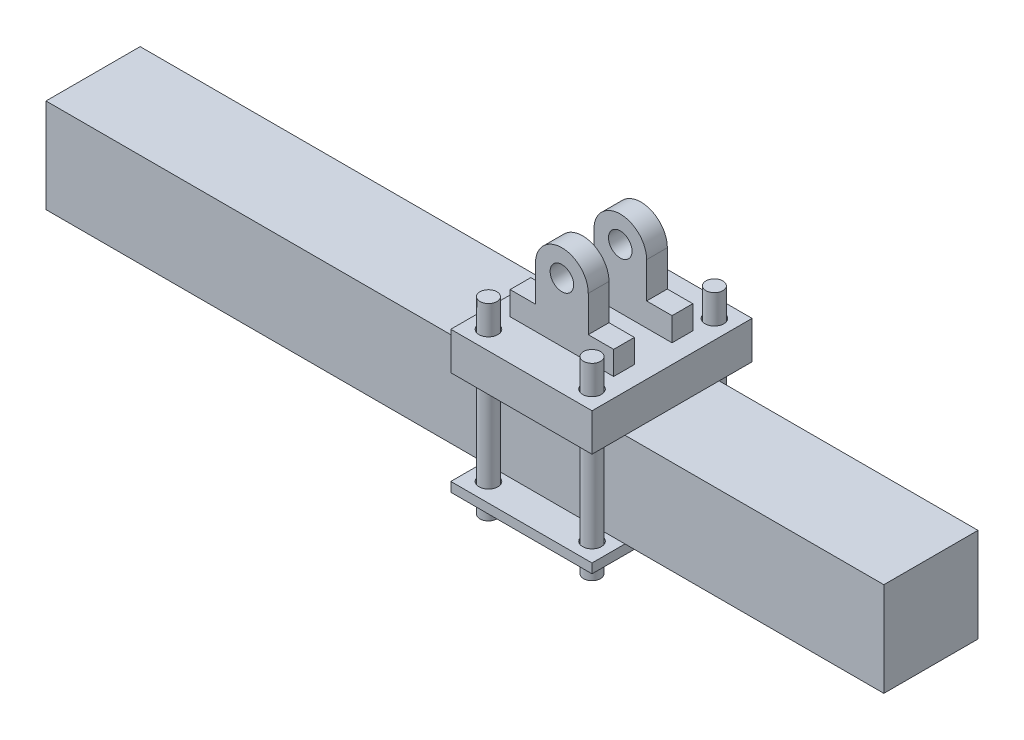
from build123d import *

# Parameters (mm, degrees)
SKETCH2_W                   = 850
SKETCH2_H                   = 100
BOSS_EXTRUDE1_DEPTH         = 50
SKETCH7_W                   = 840
SKETCH7_H                   = 90
CUT_EXTRUDE2_DEPTH          = 45
SKETCH12_W                  = 150
SKETCH12_H                  = 40
SKETCH12_H_2                = 10
BOSS_EXTRUDE9_DEPTH         = 85
SKETCH5_W                   = 100
SKETCH5_H                   = 100
BOSS_EXTRUDE4_DEPTH         = 40
CUT_EXTRUDE3_DEPTH          = 866.635604628
CUT_EXTRUDE3_DEPTH_BACK     = 866.635604628
SKETCH13_R                  = 10
BOSS_EXTRUDE10_DEPTH        = 170
BOSS_EXTRUDE10_DEPTH_BACK   = 30
SKETCH14_R                  = 9
BOSS_EXTRUDE10_2_DEPTH      = 170
BOSS_EXTRUDE10_2_DEPTH_BACK = 30
BOSS_EXTRUDE10_3_DEPTH      = 170
BOSS_EXTRUDE10_3_DEPTH_BACK = 30
BOSS_EXTRUDE10_4_DEPTH      = 170
BOSS_EXTRUDE10_4_DEPTH_BACK = 30
SKETCH15_R                  = 12.5
BOSS_EXTRUDE11_DEPTH        = 22


with BuildPart() as part:
    # Sketch2 → Boss-Extrude1 (new, symmetric)
    with BuildSketch(Plane.XY):
        with Locations((425, 50)):
            Rectangle(SKETCH2_W, SKETCH2_H)
    extrude(amount=BOSS_EXTRUDE1_DEPTH, both=True)

    # Sketch7 → Cut-Extrude2 (cut, symmetric)
    with BuildSketch(Plane.XY):
        with Locations((425, 50)):
            Rectangle(SKETCH7_W, SKETCH7_H)
    extrude(amount=CUT_EXTRUDE2_DEPTH, both=True, mode=Mode.SUBTRACT)

    # Sketch12 → Boss-Extrude9 (add, symmetric)
    with BuildSketch(Plane.XY):
        with Locations((500, 120)):
            Rectangle(SKETCH12_W, SKETCH12_H)
        with Locations((500, -5)):
            Rectangle(SKETCH12_W, SKETCH12_H_2)
    extrude(amount=BOSS_EXTRUDE9_DEPTH, both=True)

    # Sketch5 → Boss-Extrude4 (add)
    with BuildSketch(Plane.ZY):
        with Locations((0, 50)):
            Rectangle(SKETCH5_W, SKETCH5_H)
    extrude(amount=BOSS_EXTRUDE4_DEPTH)

    # Sketch13 → Cut-Extrude3 (cut, two sides: drawn at the far end of the back side and taken through both)
    with BuildSketch(Plane(origin=(0, 0, 0), x_dir=(1, 0, 0), z_dir=(0, 1, 0)).offset(-CUT_EXTRUDE3_DEPTH_BACK)):
        with Locations((555, 65)):
            Circle(SKETCH13_R)
        with Locations((445, 65)):
            Circle(SKETCH13_R)
        with Locations((445, -65)):
            Circle(SKETCH13_R)
        with Locations((555, -65)):
            Circle(SKETCH13_R)
    extrude(amount=CUT_EXTRUDE3_DEPTH + CUT_EXTRUDE3_DEPTH_BACK, mode=Mode.SUBTRACT)

    # Sketch15 → Boss-Extrude11 (add)
    with BuildSketch(Plane.XY.offset(20)):
        with BuildLine():
            Line((555, 140), (555, 165))
            Line((555, 165), (528, 165))
            Line((528, 165), (528, 203))
            ThreePointArc((528, 203), (500, 231), (472, 203))
            Line((472, 203), (472, 165))
            Line((472, 165), (445, 165))
            Line((445, 165), (445, 140))
            Line((445, 140), (555, 140))
        make_face()
        with Locations((500, 203)):
            Circle(SKETCH15_R, mode=Mode.SUBTRACT)
    boss_extrude11 = extrude(amount=BOSS_EXTRUDE11_DEPTH)

    # Mirror2: Boss-Extrude11 across plane
    add(boss_extrude11.mirror(Plane.XY))


with BuildPart() as body_2:
    # Sketch14 → Boss-Extrude10 (new, two sides: drawn at the far end of the back side and taken through both)
    with BuildSketch(Plane(origin=(0, 0, 0), x_dir=(1, 0, 0), z_dir=(0, 1, 0)).offset(-BOSS_EXTRUDE10_DEPTH_BACK)):
        with Locations((555, 65)):
            Circle(SKETCH14_R)
    extrude(amount=BOSS_EXTRUDE10_DEPTH + BOSS_EXTRUDE10_DEPTH_BACK)


with BuildPart() as body_3:
    # Sketch14 → Boss-Extrude10 2 (new, two sides: drawn at the far end of the back side and taken through both)
    with BuildSketch(Plane(origin=(0, 0, 0), x_dir=(1, 0, 0), z_dir=(0, 1, 0)).offset(-BOSS_EXTRUDE10_2_DEPTH_BACK)):
        with Locations((445, 65)):
            Circle(SKETCH14_R)
    extrude(amount=BOSS_EXTRUDE10_2_DEPTH + BOSS_EXTRUDE10_2_DEPTH_BACK)


with BuildPart() as body_4:
    # Sketch14 → Boss-Extrude10 3 (new, two sides: drawn at the far end of the back side and taken through both)
    with BuildSketch(Plane(origin=(0, 0, 0), x_dir=(1, 0, 0), z_dir=(0, 1, 0)).offset(-BOSS_EXTRUDE10_3_DEPTH_BACK)):
        with Locations((445, -65)):
            Circle(SKETCH14_R)
    extrude(amount=BOSS_EXTRUDE10_3_DEPTH + BOSS_EXTRUDE10_3_DEPTH_BACK)


with BuildPart() as body_5:
    # Sketch14 → Boss-Extrude10 4 (new, two sides: drawn at the far end of the back side and taken through both)
    with BuildSketch(Plane(origin=(0, 0, 0), x_dir=(1, 0, 0), z_dir=(0, 1, 0)).offset(-BOSS_EXTRUDE10_4_DEPTH_BACK)):
        with Locations((555, -65)):
            Circle(SKETCH14_R)
    extrude(amount=BOSS_EXTRUDE10_4_DEPTH + BOSS_EXTRUDE10_4_DEPTH_BACK)


solid = Compound([part.part, body_2.part, body_3.part, body_4.part, body_5.part])
